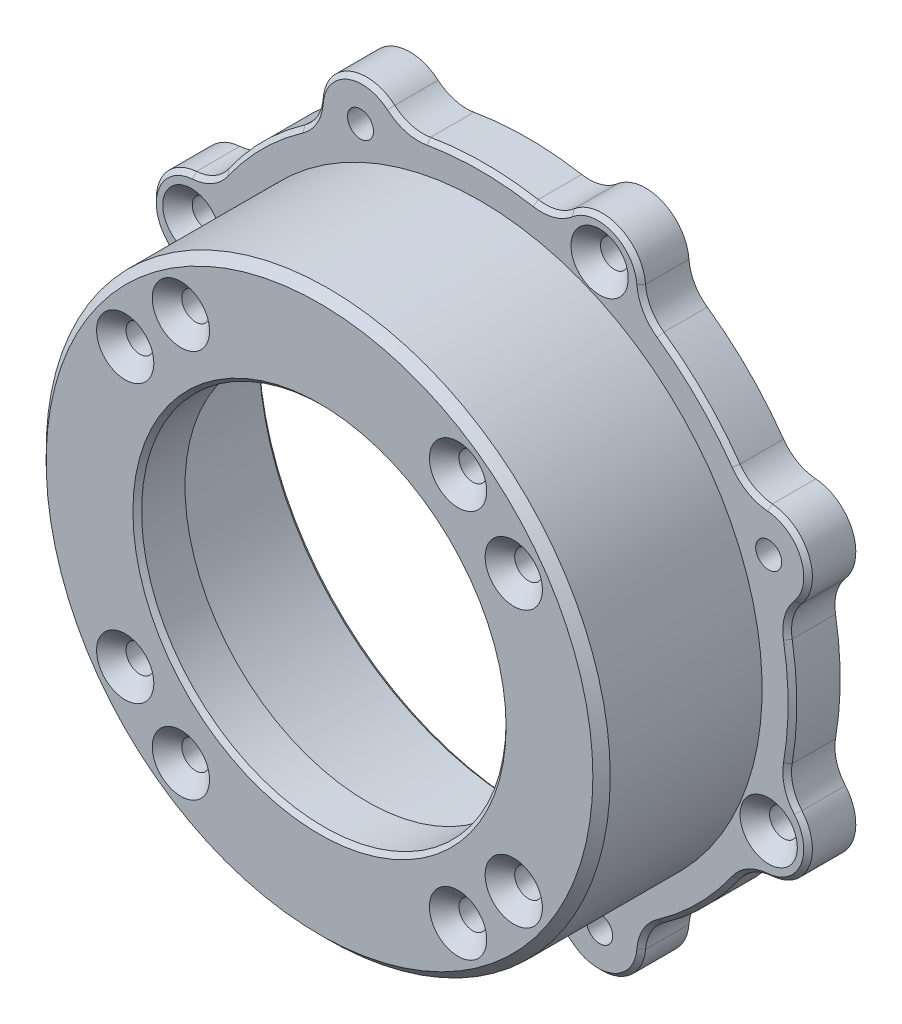
from build123d import *

# Parameters (mm, degrees)
SKETCH_2_R                = 32.5
SKETCH_2_R_2              = 1.5
SKETCH_2_R_3              = 21
EXTRUDE_1_DEPTH           = 5.5
SKETCH_3_R                = 32.5
SKETCH_3_R_2              = 30.5
EXTRUDE_2_DEPTH           = 18.5
SKETCH_4_R                = 1.5
SKETCH_4_R_2              = 30.5
EXTRUDE_3_DEPTH           = 5.5
CHAMFER_1_SIZE            = 1
CHAMFER_3_SIZE            = 0.5
HOLE_WIZARD_0_D           = 3.2
HOLE_WIZARD_0_DEPTH       = 8.1
HOLE_WIZARD_0_CSINK_D     = 6.6
HOLE_WIZARD_0_CSINK_ANGLE = 90
HOLE_WIZARD_0_TIP         = 0.96137699
HOLE_WIZARD_1_D           = 3.2
HOLE_WIZARD_1_DEPTH       = 8.1
HOLE_WIZARD_1_CSINK_D     = 6.6
HOLE_WIZARD_1_CSINK_ANGLE = 90
HOLE_WIZARD_1_TIP         = 0.96137699


with BuildPart() as part:
    # 草图2 → 凸台-拉伸1 (new body)
    with BuildSketch(Plane.XY):
        Circle(SKETCH_2_R)
        with Locations((-15.969331282, -22.388176755)):
            Circle(SKETCH_2_R_2, mode=Mode.SUBTRACT)
        with Locations((-22.388176755, -15.969331282)):
            Circle(SKETCH_2_R_2, mode=Mode.SUBTRACT)
        with Locations((-22.388176755, 15.969331282)):
            Circle(SKETCH_2_R_2, mode=Mode.SUBTRACT)
        with Locations((-15.969331282, 22.388176755)):
            Circle(SKETCH_2_R_2, mode=Mode.SUBTRACT)
        with Locations((15.969331282, 22.388176755)):
            Circle(SKETCH_2_R_2, mode=Mode.SUBTRACT)
        with Locations((22.388176755, 15.969331282)):
            Circle(SKETCH_2_R_2, mode=Mode.SUBTRACT)
        with Locations((22.388176755, -15.969331282)):
            Circle(SKETCH_2_R_2, mode=Mode.SUBTRACT)
        with Locations((15.969331282, -22.388176755)):
            Circle(SKETCH_2_R_2, mode=Mode.SUBTRACT)
        Circle(SKETCH_2_R_3, mode=Mode.SUBTRACT)
    extrude(amount=EXTRUDE_1_DEPTH)

    # 草图3 → 凸台-拉伸2 (add)
    with BuildSketch(Plane(origin=(0, 0, 0), x_dir=(-1, 0, 0), z_dir=(0, 0, -1))):
        Circle(SKETCH_3_R)
        Circle(SKETCH_3_R_2, mode=Mode.SUBTRACT)
    extrude(amount=EXTRUDE_2_DEPTH)

    # 草图4 → 凸台-拉伸3 (add)
    with BuildSketch(Plane(origin=(0, 0, -18.5), x_dir=(-1, 0, 0), z_dir=(0, 0, -1))):
        with BuildLine():
            ThreePointArc((-10.328522738, 36.591619506), (-15.498679334, 37.417120933), (-18.570814392, 33.177550434))
            ThreePointArc((-18.570814392, 33.177550434), (-19.210808968, 31.084296828), (-20.683639012, 29.465014462))
            ThreePointArc((-20.683639012, 29.465014462), (-25.455844342, 25.455843903), (-29.465014819, 20.683638503))
            ThreePointArc((-29.465014819, 20.683638503), (-31.084297159, 19.210808432), (-33.177550755, 18.570813819))
            ThreePointArc((-33.177550755, 18.570813819), (-37.4171212, 15.498678688), (-36.591619684, 10.328522106))
            ThreePointArc((-36.591619684, 10.328522106), (-35.564010369, 8.395823782), (-35.460452938, 6.209370129))
            ThreePointArc((-35.460452938, 6.209370129), (-36, -3.11e-07), (-35.460452831, -6.209370741))
            ThreePointArc((-35.460452831, -6.209370741), (-35.564010224, -8.395824396), (-36.591619506, -10.328522738))
            ThreePointArc((-36.591619506, -10.328522738), (-37.417120933, -15.498679334), (-33.177550434, -18.570814392))
            ThreePointArc((-33.177550434, -18.570814392), (-31.084296828, -19.210808968), (-29.465014462, -20.683639012))
            ThreePointArc((-29.465014462, -20.683639012), (-25.455843903, -25.455844342), (-20.683638503, -29.465014819))
            ThreePointArc((-20.683638503, -29.465014819), (-19.210808432, -31.084297159), (-18.57081382, -33.177550755))
            ThreePointArc((-18.57081382, -33.177550755), (-15.498678688, -37.4171212), (-10.328522106, -36.591619684))
            ThreePointArc((-10.328522106, -36.591619684), (-8.395823782, -35.564010369), (-6.209370129, -35.460452938))
            ThreePointArc((-6.209370129, -35.460452938), (3.11e-07, -36), (6.209370741, -35.460452831))
            ThreePointArc((6.209370741, -35.460452831), (8.395824396, -35.564010224), (10.328522738, -36.591619506))
            ThreePointArc((10.328522738, -36.591619506), (15.498679334, -37.417120933), (18.570814392, -33.177550434))
            ThreePointArc((18.570814392, -33.177550434), (19.210808968, -31.084296828), (20.683639012, -29.465014462))
            ThreePointArc((20.683639012, -29.465014462), (25.455844342, -25.455843903), (29.465014819, -20.683638503))
            ThreePointArc((29.465014819, -20.683638503), (31.084297159, -19.210808432), (33.177550755, -18.57081382))
            ThreePointArc((33.177550755, -18.57081382), (37.4171212, -15.498678688), (36.591619684, -10.328522106))
            ThreePointArc((36.591619684, -10.328522106), (35.564010369, -8.395823782), (35.460452938, -6.209370129))
            ThreePointArc((35.460452938, -6.209370129), (36, 3.11e-07), (35.460452831, 6.209370741))
            ThreePointArc((35.460452831, 6.209370741), (35.564010224, 8.395824396), (36.591619506, 10.328522738))
            ThreePointArc((36.591619506, 10.328522738), (37.417120933, 15.498679334), (33.177550434, 18.570814392))
            ThreePointArc((33.177550434, 18.570814392), (31.084296828, 19.210808968), (29.465014462, 20.683639012))
            ThreePointArc((29.465014462, 20.683639012), (25.455843903, 25.455844342), (20.683638503, 29.465014819))
            ThreePointArc((20.683638503, 29.465014819), (19.210808432, 31.084297159), (18.57081382, 33.177550755))
            ThreePointArc((18.57081382, 33.177550755), (15.498678688, 37.4171212), (10.328522106, 36.591619684))
            ThreePointArc((10.328522106, 36.591619684), (8.395823782, 35.564010369), (6.209370129, 35.460452938))
            ThreePointArc((6.209370129, 35.460452938), (-3.11e-07, 36), (-6.209370741, 35.460452831))
            ThreePointArc((-6.209370741, 35.460452831), (-8.395824396, 35.564010224), (-10.328522738, 36.591619506))
        make_face()
        with Locations((-13.776603852, 33.259663052)):
            Circle(SKETCH_4_R, mode=Mode.SUBTRACT)
        with Locations((13.776603278, 33.259663289)):
            Circle(SKETCH_4_R, mode=Mode.SUBTRACT)
        with Locations((33.259663052, 13.776603852)):
            Circle(SKETCH_4_R, mode=Mode.SUBTRACT)
        with Locations((33.259663289, -13.776603278)):
            Circle(SKETCH_4_R, mode=Mode.SUBTRACT)
        with Locations((13.776603852, -33.259663052)):
            Circle(SKETCH_4_R, mode=Mode.SUBTRACT)
        with Locations((-13.776603278, -33.259663289)):
            Circle(SKETCH_4_R, mode=Mode.SUBTRACT)
        with Locations((-33.259663052, -13.776603852)):
            Circle(SKETCH_4_R, mode=Mode.SUBTRACT)
        with Locations((-33.259663289, 13.776603278)):
            Circle(SKETCH_4_R, mode=Mode.SUBTRACT)
        Circle(SKETCH_4_R_2, mode=Mode.SUBTRACT)
    extrude(amount=-EXTRUDE_3_DEPTH)

    # 倒角1
    chamfer_1_edges = [part.edges().sort_by_distance(p)[0] for p in [
        (-32.5, 0, 5.5),
    ]]
    chamfer(chamfer_1_edges, length=CHAMFER_1_SIZE)

    # 倒角3
    chamfer_3_edges = [part.edges().sort_by_distance(p)[0] for p in [
        (-21, 0, 5.5),
        (30.5, 0, -18.5),
        (8.395824396, 35.564010224, -13),
        (3.11e-07, 36, -13),
        (-8.395823782, 35.564010369, -13),
        (-15.498678688, 37.4171212, -13),
        (-19.210808432, 31.084297159, -13),
        (-25.455843903, 25.455844342, -13),
        (-31.084296828, 19.210808968, -13),
        (-37.417120933, 15.498679334, -13),
        (-35.564010224, 8.395824396, -13),
        (-36, 3.11e-07, -13),
        (-35.564010369, -8.395823782, -13),
        (-37.4171212, -15.498678688, -13),
        (-31.084297159, -19.210808432, -13),
        (-25.455844342, -25.455843903, -13),
        (-19.210808968, -31.084296828, -13),
        (-15.498679334, -37.417120933, -13),
        (-8.395824396, -35.564010224, -13),
        (-3.11e-07, -36, -13),
        (8.395823782, -35.564010369, -13),
        (15.498678688, -37.4171212, -13),
        (19.210808432, -31.084297159, -13),
        (25.455843903, -25.455844342, -13),
        (31.084296828, -19.210808968, -13),
        (37.417120933, -15.498679334, -13),
        (35.564010224, -8.395824396, -13),
        (36, -3.11e-07, -13),
        (35.564010369, 8.395823782, -13),
        (37.4171212, 15.498678688, -13),
        (31.084297159, 19.210808432, -13),
        (25.455844342, 25.455843903, -13),
        (19.210808968, 31.084296828, -13),
        (15.498679334, 37.417120933, -13),
    ]]
    chamfer(chamfer_3_edges, length=CHAMFER_3_SIZE)

    # 打孔尺寸(%根据十字)槽沉头木螺钉的类型0
    with Locations(Plane.XY.offset(-13)):
        with Locations((13.776603852, 33.259663052), (33.259663052, -13.776603852), (-13.776603852, -33.259663052), (-33.259663052, 13.776603852)):
            CounterSinkHole(HOLE_WIZARD_0_D / 2, HOLE_WIZARD_0_CSINK_D / 2, depth=HOLE_WIZARD_0_DEPTH, counter_sink_angle=HOLE_WIZARD_0_CSINK_ANGLE)
            with Locations((0, 0, -(HOLE_WIZARD_0_DEPTH + HOLE_WIZARD_0_TIP / 2))):  # 118° drill point
                Cone(0, HOLE_WIZARD_0_D / 2, HOLE_WIZARD_0_TIP, mode=Mode.SUBTRACT)

    # 打孔尺寸(%根据十字)槽沉头木螺钉的类型1
    with Locations(Plane.XY.offset(5.5)):
        with Locations((-15.969331282, 22.388176755), (-22.388176755, 15.969331282), (-22.388176755, -15.969331282), (-15.969331282, -22.388176755), (15.969331282, -22.388176755), (22.388176755, -15.969331282), (22.388176755, 15.746279838), (15.969331282, 22.388176755)):
            CounterSinkHole(HOLE_WIZARD_1_D / 2, HOLE_WIZARD_1_CSINK_D / 2, depth=HOLE_WIZARD_1_DEPTH, counter_sink_angle=HOLE_WIZARD_1_CSINK_ANGLE)
            with Locations((0, 0, -(HOLE_WIZARD_1_DEPTH + HOLE_WIZARD_1_TIP / 2))):  # 118° drill point
                Cone(0, HOLE_WIZARD_1_D / 2, HOLE_WIZARD_1_TIP, mode=Mode.SUBTRACT)


solid = part.part
